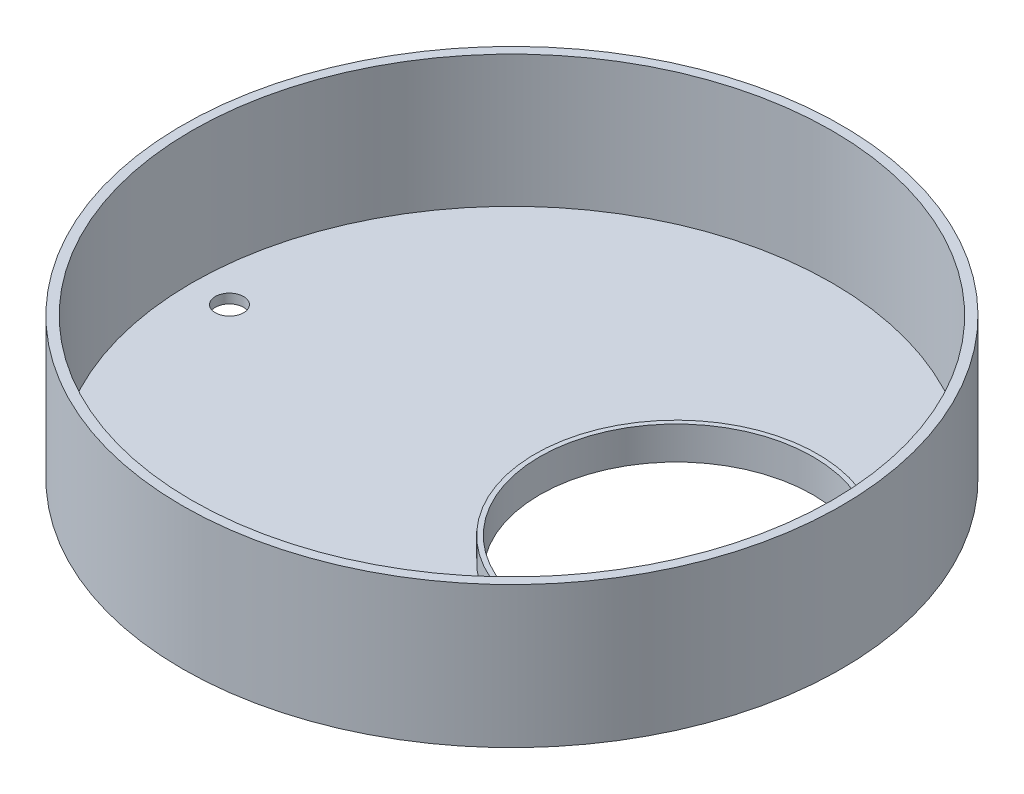
from build123d import *

# Parameters (mm, degrees)
SKETCH1_R           = 70
BOSS_EXTRUDE1_DEPTH = 30
SHELL1_T            = -2
SKETCH2_R           = 33
SKETCH2_R_2         = 29
EXTRUDE_THIN1_DEPTH = 5
SKETCH3_R           = 33
SKETCH3_R_2         = 30
CUT_EXTRUDE1_DEPTH  = 5
SKETCH4_R           = 29
CUT_EXTRUDE2_DEPTH  = 2
SKETCH5_R           = 3
CUT_EXTRUDE3_DEPTH  = 5


with BuildPart() as part:
    # Sketch1 → Boss-Extrude1 (new body)
    with BuildSketch(Plane(origin=(0, 0, 0), x_dir=(1, 0, 0), z_dir=(0, 1, 0))):
        with Locations(Location((0, 0, 0), (0, 0, 270))):
            Circle(SKETCH1_R)
    extrude(amount=BOSS_EXTRUDE1_DEPTH)

    # Shell1
    shell1_openings = [part.faces().sort_by_distance(p)[0] for p in [
        (0, 30, 0),
    ]]
    offset(amount=SHELL1_T, openings=shell1_openings, kind=Kind.INTERSECTION)

    # Sketch2 → Extrude-Thin1 (add)
    with BuildSketch(Plane(origin=(0, 2, 0), x_dir=(1, 0, 0), z_dir=(0, 1, 0))):
        with Locations((34.921312676, 0)):
            Circle(SKETCH2_R)
        with Locations((34.921312676, 0)):
            Circle(SKETCH2_R_2, mode=Mode.SUBTRACT)
    extrude(amount=EXTRUDE_THIN1_DEPTH)

    # Sketch3 → Cut-Extrude1 (cut)
    with BuildSketch(Plane(origin=(0, 7, 0), x_dir=(1, 0, 0), z_dir=(0, 1, 0))):
        with Locations((34.921312676, 0)):
            Circle(SKETCH3_R)
        with Locations(Location((34.921312676, 0, 0), (0, 0, 270))):
            Circle(SKETCH3_R_2, mode=Mode.SUBTRACT)
    extrude(amount=-CUT_EXTRUDE1_DEPTH, mode=Mode.SUBTRACT)

    # Sketch4 → Cut-Extrude2 (cut)
    with BuildSketch(Plane(origin=(0, 2, 0), x_dir=(1, 0, 0), z_dir=(0, 1, 0))):
        with Locations(Location((34.921312676, 0, 0), (0, 0, 270))):
            Circle(SKETCH4_R)
    extrude(amount=-CUT_EXTRUDE2_DEPTH, mode=Mode.SUBTRACT)

    # Sketch5 → Cut-Extrude3 (cut, symmetric)
    with BuildSketch(Plane(origin=(0, 2, 0), x_dir=(1, 0, 0), z_dir=(0, 1, 0))):
        with Locations(Location((-60, 0, 0), (0, 0, 270))):
            Circle(SKETCH5_R)
    extrude(amount=CUT_EXTRUDE3_DEPTH, both=True, mode=Mode.SUBTRACT)


solid = part.part
